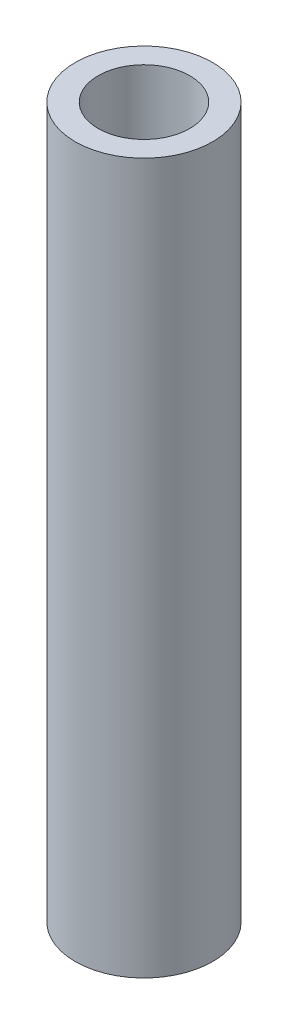
from build123d import *

# Parameters (mm, degrees)
SKETCH1_R           = 6
SKETCH1_R_2         = 4
BOSS_EXTRUDE1_DEPTH = 62


with BuildPart() as part:
    # Sketch1 → Boss-Extrude1 (new body)
    with BuildSketch(Plane(origin=(0, 0, 0), x_dir=(1, 0, 0), z_dir=(0, 1, 0))):
        Circle(SKETCH1_R)
        Circle(SKETCH1_R_2, mode=Mode.SUBTRACT)
    extrude(amount=BOSS_EXTRUDE1_DEPTH)


solid = part.part
